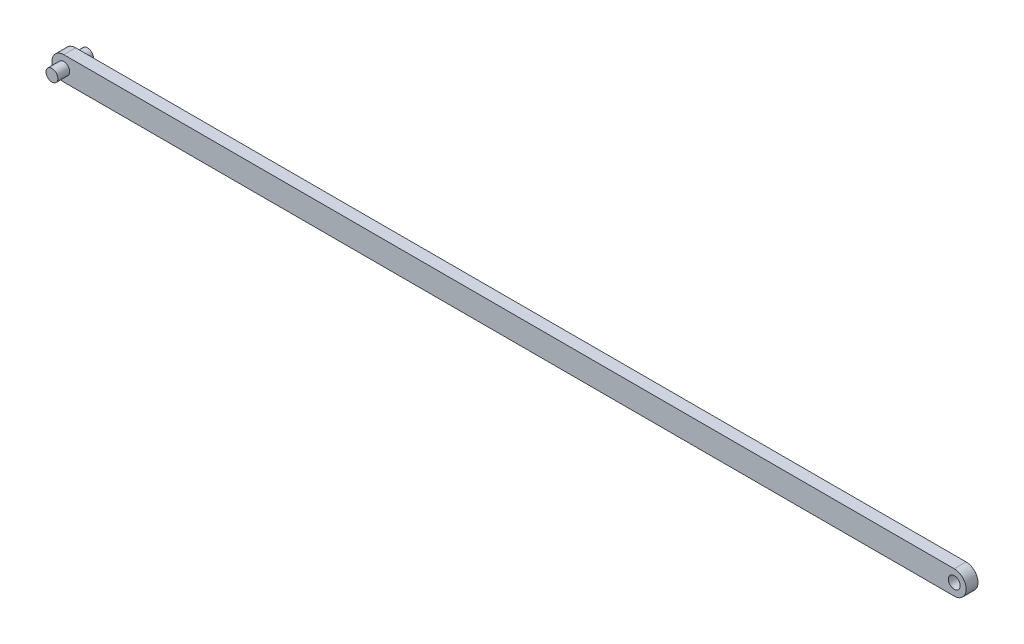
from build123d import *

# Parameters (mm, degrees)
SKETCH_1_R           = 1
EXTRUDE_1_DEPTH      = 2
SKETCH_2_R           = 1
EXTRUDE_2_DEPTH      = 2
EXTRUDE_2_DEPTH_BACK = 4


with BuildPart() as part:
    # 草图1 → 凸台-拉伸1 (new body)
    with BuildSketch(Plane.XY):
        with BuildLine():
            Line((-50.159162871, -2), (99.840837129, -2))
            ThreePointArc((99.840837129, -2), (101.840837129, 0), (99.840837129, 2))
            Line((99.840837129, 2), (-50.159162871, 2))
            ThreePointArc((-50.159162871, 2), (-52.159162871, 0), (-50.159162871, -2))
        make_face()
        with Locations((99.840837129, 0)):
            Circle(SKETCH_1_R, mode=Mode.SUBTRACT)
    extrude(amount=EXTRUDE_1_DEPTH)

    # 草图2 → 凸台-拉伸2 (add, two sides)
    with BuildSketch(Plane.XY.offset(2)) as extrude_2_sk:
        with Locations((-50.159162871, 0)):
            Circle(SKETCH_2_R)
    extrude(amount=EXTRUDE_2_DEPTH)
    extrude(extrude_2_sk.sketch, amount=-EXTRUDE_2_DEPTH_BACK)


solid = part.part
